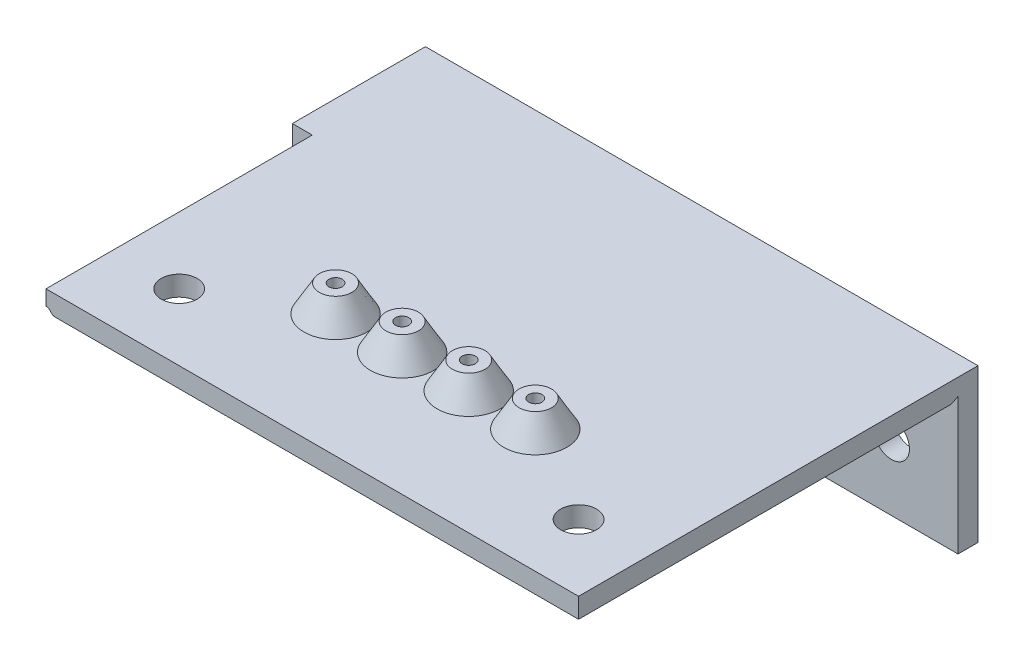
from build123d import *

# Parameters (mm, degrees)
SKETCH1_W                      = 80
SKETCH1_H                      = 20
SKETCH1_R                      = 2.7
BOSS_EXTRUDE1_DEPTH            = 3
BOSS_EXTRUDE2_DEPTH            = 20
SKETCH2_W                      = 80
SKETCH2_H                      = 3
BOSS_EXTRUDE3_DEPTH            = 40
SKETCH3_R                      = 4.75
BOSS_EXTRUDE5_DEPTH            = 4
BOSS_EXTRUDE5_TAPER            = 30
CUT_EXTRUDE2_REACH             = 25
SKETCH3_6_R                    = 1
SKETCH3_6_R_2                  = 2.7
CUT_EXTRUDE2_DIRECTION_2_REACH = 6
CUT_EXTRUDE3_DEPTH             = 57
CUT_EXTRUDE4_DEPTH             = 20
CUT_EXTRUDE5_DEPTH             = 80


with BuildPart() as part:
    # Sketch1 → Boss-Extrude1 (new body)
    with BuildSketch(Plane.XY):
        Rectangle(SKETCH1_W, SKETCH1_H)
        with Locations((-30, 0)):
            Circle(SKETCH1_R, mode=Mode.SUBTRACT)
        with Locations((-10, 0)):
            Circle(SKETCH1_R, mode=Mode.SUBTRACT)
        with Locations((10, 0)):
            Circle(SKETCH1_R, mode=Mode.SUBTRACT)
        with Locations((30, 0)):
            Circle(SKETCH1_R, mode=Mode.SUBTRACT)
    extrude(amount=BOSS_EXTRUDE1_DEPTH)

    # Sketch1_3 → Boss-Extrude2 (add)
    with BuildSketch(Plane.XY):
        Polygon((40, 13), (40, 10), (-40, 10), (-40, -10), (-43, -10), (-43, 13), align=None)
    extrude(amount=BOSS_EXTRUDE2_DEPTH)

    # Sketch2 → Boss-Extrude3 (add)
    with BuildSketch(Plane.XY.offset(20)):
        with Locations((0, 11.5)):
            Rectangle(SKETCH2_W, SKETCH2_H)
    extrude(amount=BOSS_EXTRUDE3_DEPTH)

    # Sketch3 → Boss-Extrude5 (add)
    with BuildSketch(Plane.XZ.offset(-13)):
        with Locations((15, 41.5)):
            Circle(SKETCH3_R)
        with Locations((5, 41.5)):
            Circle(SKETCH3_R)
        with Locations((-5, 41.5)):
            Circle(SKETCH3_R)
        with Locations((-15, 41.5)):
            Circle(SKETCH3_R)
    extrude(amount=-BOSS_EXTRUDE5_DEPTH, taper=BOSS_EXTRUDE5_TAPER)

    # Cut-Extrude2: up to this face of the body (flat: up to its plane)
    cut_extrude2_end = Plane(part.part.faces().sort_by_distance((0, 10, 31.5))[0])
    # Sketch3_6 → Cut-Extrude2 (cut, up to the picked face)
    with BuildSketch(Plane.XZ.offset(-13), mode=Mode.PRIVATE) as cut_extrude2_sk1:
        with Locations((-15, 41.5)):
            Circle(SKETCH3_6_R)
    cut_extrude2_tool1 = split(extrude(cut_extrude2_sk1.sketch, amount=CUT_EXTRUDE2_REACH, mode=Mode.PRIVATE), bisect_by=cut_extrude2_end, keep=Keep.BOTH, mode=Mode.PRIVATE)
    add(cut_extrude2_tool1.solids().sort_by_distance((-15, 13, 41.5))[0], mode=Mode.SUBTRACT)
    # Sketch3_6 → Cut-Extrude2 (cut, up to the picked face)
    with BuildSketch(Plane.XZ.offset(-13), mode=Mode.PRIVATE) as cut_extrude2_sk2:
        with Locations((5, 41.5)):
            Circle(SKETCH3_6_R)
    cut_extrude2_tool2 = split(extrude(cut_extrude2_sk2.sketch, amount=CUT_EXTRUDE2_REACH, mode=Mode.PRIVATE), bisect_by=cut_extrude2_end, keep=Keep.BOTH, mode=Mode.PRIVATE)
    add(cut_extrude2_tool2.solids().sort_by_distance((5, 13, 41.5))[0], mode=Mode.SUBTRACT)
    # Sketch3_6 → Cut-Extrude2 (cut, up to the picked face)
    with BuildSketch(Plane.XZ.offset(-13), mode=Mode.PRIVATE) as cut_extrude2_sk3:
        with Locations((-30, 50)):
            Circle(SKETCH3_6_R_2)
    cut_extrude2_tool3 = split(extrude(cut_extrude2_sk3.sketch, amount=CUT_EXTRUDE2_REACH, mode=Mode.PRIVATE), bisect_by=cut_extrude2_end, keep=Keep.BOTH, mode=Mode.PRIVATE)
    add(cut_extrude2_tool3.solids().sort_by_distance((-30, 13, 50))[0], mode=Mode.SUBTRACT)
    # Sketch3_6 → Cut-Extrude2 (cut, up to the picked face)
    with BuildSketch(Plane.XZ.offset(-13), mode=Mode.PRIVATE) as cut_extrude2_sk4:
        with Locations((30, 50)):
            Circle(SKETCH3_6_R_2)
    cut_extrude2_tool4 = split(extrude(cut_extrude2_sk4.sketch, amount=CUT_EXTRUDE2_REACH, mode=Mode.PRIVATE), bisect_by=cut_extrude2_end, keep=Keep.BOTH, mode=Mode.PRIVATE)
    add(cut_extrude2_tool4.solids().sort_by_distance((30, 13, 50))[0], mode=Mode.SUBTRACT)
    # Sketch3_6 → Cut-Extrude2 (cut, up to the picked face)
    with BuildSketch(Plane.XZ.offset(-13), mode=Mode.PRIVATE) as cut_extrude2_sk5:
        with Locations((15, 41.5)):
            Circle(SKETCH3_6_R)
    cut_extrude2_tool5 = split(extrude(cut_extrude2_sk5.sketch, amount=CUT_EXTRUDE2_REACH, mode=Mode.PRIVATE), bisect_by=cut_extrude2_end, keep=Keep.BOTH, mode=Mode.PRIVATE)
    add(cut_extrude2_tool5.solids().sort_by_distance((15, 13, 41.5))[0], mode=Mode.SUBTRACT)
    # Sketch3_6 → Cut-Extrude2 (cut, up to the picked face)
    with BuildSketch(Plane.XZ.offset(-13), mode=Mode.PRIVATE) as cut_extrude2_sk6:
        with Locations((-5, 41.5)):
            Circle(SKETCH3_6_R)
    cut_extrude2_tool6 = split(extrude(cut_extrude2_sk6.sketch, amount=CUT_EXTRUDE2_REACH, mode=Mode.PRIVATE), bisect_by=cut_extrude2_end, keep=Keep.BOTH, mode=Mode.PRIVATE)
    add(cut_extrude2_tool6.solids().sort_by_distance((-5, 13, 41.5))[0], mode=Mode.SUBTRACT)

    # Cut-Extrude2 direction 2: up to this face of the body (flat: up to its plane)
    cut_extrude2_direction_2_end = Plane(part.part.faces().sort_by_distance((-15, 17, 41.5))[0])
    # Sketch3_6 → Cut-Extrude2 direction 2 (cut, up to the picked face)
    with BuildSketch(Plane.XZ.offset(-13), mode=Mode.PRIVATE) as cut_extrude2_direction_2_sk1:
        with Locations((-15, 41.5)):
            Circle(SKETCH3_6_R)
    cut_extrude2_direction_2_tool1 = split(extrude(cut_extrude2_direction_2_sk1.sketch, amount=-CUT_EXTRUDE2_DIRECTION_2_REACH, mode=Mode.PRIVATE), bisect_by=cut_extrude2_direction_2_end, keep=Keep.BOTH, mode=Mode.PRIVATE)
    add(cut_extrude2_direction_2_tool1.solids().sort_by_distance((-15, 13, 41.5))[0], mode=Mode.SUBTRACT)
    # Sketch3_6 → Cut-Extrude2 direction 2 (cut, up to the picked face)
    with BuildSketch(Plane.XZ.offset(-13), mode=Mode.PRIVATE) as cut_extrude2_direction_2_sk2:
        with Locations((5, 41.5)):
            Circle(SKETCH3_6_R)
    cut_extrude2_direction_2_tool2 = split(extrude(cut_extrude2_direction_2_sk2.sketch, amount=-CUT_EXTRUDE2_DIRECTION_2_REACH, mode=Mode.PRIVATE), bisect_by=cut_extrude2_direction_2_end, keep=Keep.BOTH, mode=Mode.PRIVATE)
    add(cut_extrude2_direction_2_tool2.solids().sort_by_distance((5, 13, 41.5))[0], mode=Mode.SUBTRACT)
    # Sketch3_6 → Cut-Extrude2 direction 2 (cut, up to the picked face)
    with BuildSketch(Plane.XZ.offset(-13), mode=Mode.PRIVATE) as cut_extrude2_direction_2_sk3:
        with Locations((-30, 50)):
            Circle(SKETCH3_6_R_2)
    cut_extrude2_direction_2_tool3 = split(extrude(cut_extrude2_direction_2_sk3.sketch, amount=-CUT_EXTRUDE2_DIRECTION_2_REACH, mode=Mode.PRIVATE), bisect_by=cut_extrude2_direction_2_end, keep=Keep.BOTH, mode=Mode.PRIVATE)
    add(cut_extrude2_direction_2_tool3.solids().sort_by_distance((-30, 13, 50))[0], mode=Mode.SUBTRACT)
    # Sketch3_6 → Cut-Extrude2 direction 2 (cut, up to the picked face)
    with BuildSketch(Plane.XZ.offset(-13), mode=Mode.PRIVATE) as cut_extrude2_direction_2_sk4:
        with Locations((30, 50)):
            Circle(SKETCH3_6_R_2)
    cut_extrude2_direction_2_tool4 = split(extrude(cut_extrude2_direction_2_sk4.sketch, amount=-CUT_EXTRUDE2_DIRECTION_2_REACH, mode=Mode.PRIVATE), bisect_by=cut_extrude2_direction_2_end, keep=Keep.BOTH, mode=Mode.PRIVATE)
    add(cut_extrude2_direction_2_tool4.solids().sort_by_distance((30, 13, 50))[0], mode=Mode.SUBTRACT)
    # Sketch3_6 → Cut-Extrude2 direction 2 (cut, up to the picked face)
    with BuildSketch(Plane.XZ.offset(-13), mode=Mode.PRIVATE) as cut_extrude2_direction_2_sk5:
        with Locations((15, 41.5)):
            Circle(SKETCH3_6_R)
    cut_extrude2_direction_2_tool5 = split(extrude(cut_extrude2_direction_2_sk5.sketch, amount=-CUT_EXTRUDE2_DIRECTION_2_REACH, mode=Mode.PRIVATE), bisect_by=cut_extrude2_direction_2_end, keep=Keep.BOTH, mode=Mode.PRIVATE)
    add(cut_extrude2_direction_2_tool5.solids().sort_by_distance((15, 13, 41.5))[0], mode=Mode.SUBTRACT)
    # Sketch3_6 → Cut-Extrude2 direction 2 (cut, up to the picked face)
    with BuildSketch(Plane.XZ.offset(-13), mode=Mode.PRIVATE) as cut_extrude2_direction_2_sk6:
        with Locations((-5, 41.5)):
            Circle(SKETCH3_6_R)
    cut_extrude2_direction_2_tool6 = split(extrude(cut_extrude2_direction_2_sk6.sketch, amount=-CUT_EXTRUDE2_DIRECTION_2_REACH, mode=Mode.PRIVATE), bisect_by=cut_extrude2_direction_2_end, keep=Keep.BOTH, mode=Mode.PRIVATE)
    add(cut_extrude2_direction_2_tool6.solids().sort_by_distance((-5, 13, 41.5))[0], mode=Mode.SUBTRACT)

    # Sketch4 → Cut-Extrude3 (cut)
    with BuildSketch(Plane.XY.offset(3)):
        with BuildLine():
            Line((-39.469669914, 10.530330086), (-39.085786438, 10.146446609))
            ThreePointArc((-39.085786438, 10.146446609), (-38.923574763, 10.038060234), (-38.732233047, 10))
            Line((-38.732233047, 10), (-40, 8.732233047))
            ThreePointArc((-40, 8.732233047), (-40.038060234, 8.923574763), (-40.146446609, 9.085786438))
            Line((-40.146446609, 9.085786438), (-40.530330086, 9.469669914))
            ThreePointArc((-40.530330086, 9.469669914), (-40.530330086, 10.530330086), (-39.469669914, 10.530330086))
        make_face()
    extrude(amount=CUT_EXTRUDE3_DEPTH, mode=Mode.SUBTRACT)

    # Sketch5 → Cut-Extrude4 (cut)
    with BuildSketch(Plane.XZ.offset(10)):
        Polygon((-40, 3), (-40.5, 3), (-40, 4), align=None)
    extrude(amount=-CUT_EXTRUDE4_DEPTH, mode=Mode.SUBTRACT)

    # Sketch6 → Cut-Extrude5 (cut)
    with BuildSketch(Plane(origin=(40, 0, 0), x_dir=(0, 0, -1), z_dir=(1, 0, 0))):
        Polygon((-3, 10), (-3, 10.5), (-4, 10), align=None)
    extrude(amount=-CUT_EXTRUDE5_DEPTH, mode=Mode.SUBTRACT)


solid = part.part
